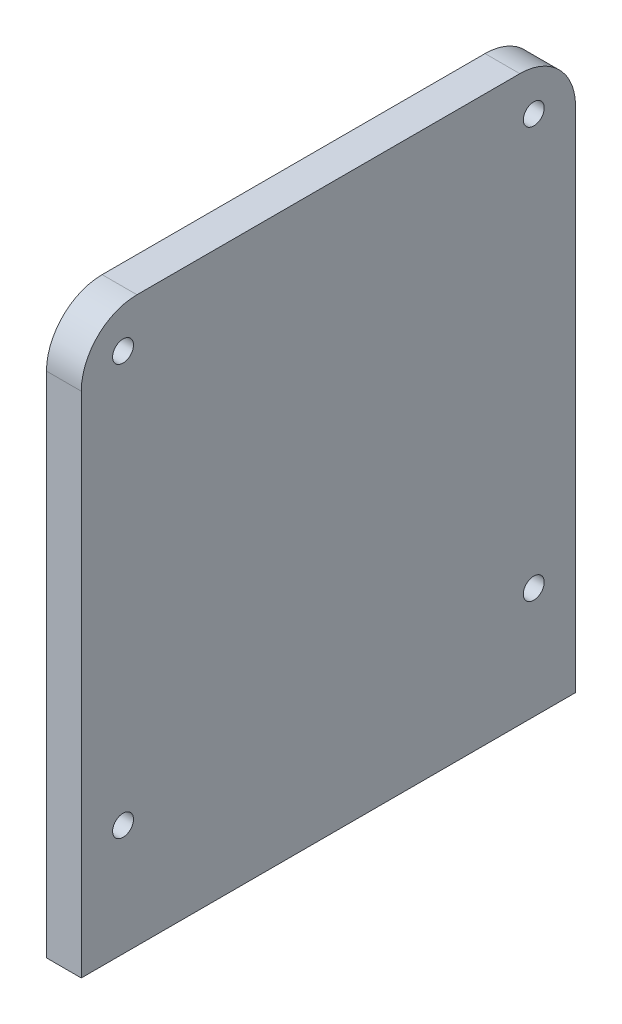
from build123d import *

# Parameters (mm, degrees)
SKETCH1_W           = 71
SKETCH1_H           = 81
SKETCH1_R           = 1.5
BOSS_EXTRUDE1_DEPTH = 5
FILLET1_R           = 8


with BuildPart() as part:
    # Sketch1 → Boss-Extrude1 (new body)
    with BuildSketch(Plane(origin=(0, 0, 0), x_dir=(0, 0, -1), z_dir=(1, 0, 0))):
        with Locations((35.5, 40.5)):
            Rectangle(SKETCH1_W, SKETCH1_H)
        with Locations((6, 75)):
            Circle(SKETCH1_R, mode=Mode.SUBTRACT)
        with Locations((65, 75)):
            Circle(SKETCH1_R, mode=Mode.SUBTRACT)
        with Locations((6, 16)):
            Circle(SKETCH1_R, mode=Mode.SUBTRACT)
        with Locations((65, 16)):
            Circle(SKETCH1_R, mode=Mode.SUBTRACT)
    extrude(amount=BOSS_EXTRUDE1_DEPTH)

    # Fillet1
    fillet1_edges = [part.edges().sort_by_distance(p)[0] for p in [
        (2.5, 81, 0),
        (2.5, 81, -71),
    ]]
    fillet(fillet1_edges, radius=FILLET1_R)


solid = part.part
